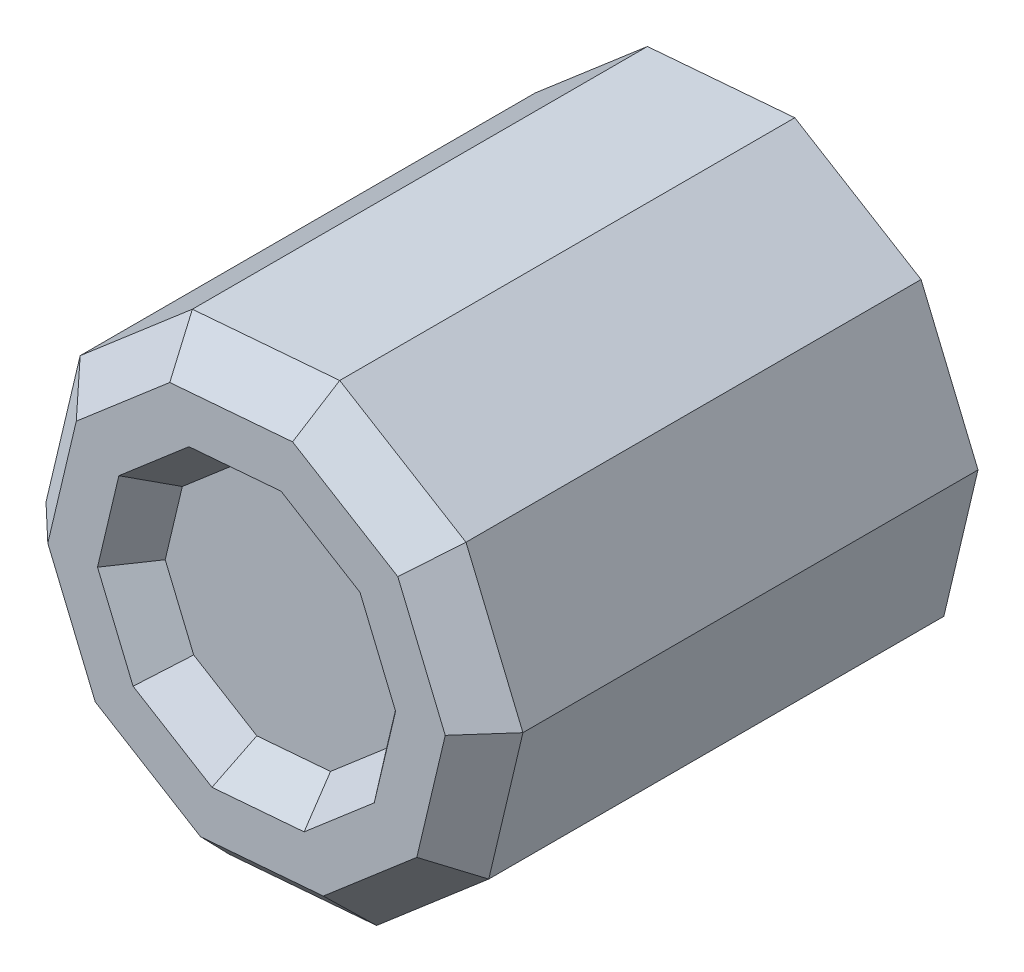
from build123d import *

# Parameters (mm, degrees)
SKETCH_1_R          = 3.05
EXTRUDE_1_DEPTH     = 12
SKETCH_2_R          = 3.098235282
EXTRUDE_2_DEPTH     = 2
EXTRUDE_3_DEPTH     = 7
CHAMFER_1_SIZE      = 1
SKETCH_6_R          = 3.05
CUT_EXTRUDE_2_DEPTH = 7
SKETCH_7_R          = 3.05
SKETCH_7_R_2        = 3
EXTRUDE_4_DEPTH     = 10
SKETCH_8_R          = 3
EXTRUDE_5_DEPTH     = 1


with BuildPart() as part:
    # 草图1 → 凸台-拉伸1 (new body)
    with BuildSketch(Plane.XY):
        Polygon((1.45714262, 6.138188374), (-2.429083459, 5.822385651), (-5.387482218, 3.282629506), (-6.288045884, -0.510979538), (-4.786789744, -4.109411766), (-1.45714262, -6.138188374), (2.429083459, -5.822385651), (5.387482218, -3.282629506), (6.288045884, 0.510979538), (4.786789744, 4.109411766), align=None)
        Circle(SKETCH_1_R, mode=Mode.SUBTRACT)
    extrude(amount=EXTRUDE_1_DEPTH)

    # 草图2 → 凸台-拉伸2 (add)
    with BuildSketch(Plane.XY.offset(12)):
        Circle(SKETCH_2_R)
    extrude(amount=-EXTRUDE_2_DEPTH)

    # 草图3 → 凸台-拉伸3 (add)
    with BuildSketch(Plane(origin=(0, 0, 10), x_dir=(-1, 0, 0), z_dir=(0, 0, -1))):
        with BuildLine():
            Line((1.45, 2.683281573), (1.45, -2.683281573))
            ThreePointArc((1.45, -2.683281573), (3.05, 0), (1.45, 2.683281573))
        make_face()
    extrude(amount=EXTRUDE_3_DEPTH)

    # 倒角1
    chamfer_1_edges = [part.edges().sort_by_distance(p)[0] for p in [
        (-3.908282839, 4.552507579, 12),
        (-5.837764051, 1.385824984, 12),
        (-5.537417814, -2.310195652, 12),
        (-3.121966182, -5.12380007, 12),
        (0.48597042, -5.980287012, 12),
        (3.908282839, -4.552507579, 12),
        (5.837764051, -1.385824984, 12),
        (5.537417814, 2.310195652, 12),
        (3.121966182, 5.12380007, 12),
        (-0.48597042, 5.980287012, 12),
    ]]
    chamfer(chamfer_1_edges, length=CHAMFER_1_SIZE)

    # 草图5 → 切除-放样1 section 0
    with BuildSketch(Plane.XY.offset(12)):
        Polygon((0.910714137, 3.836367733), (-1.518177162, 3.638991032), (-3.367176386, 2.051643441), (-3.930028677, -0.319362211), (-2.99174359, -2.568382354), (-0.910714137, -3.836367733), (1.518177162, -3.638991032), (3.367176386, -2.051643441), (3.930028677, 0.319362211), (2.99174359, 2.568382354), align=None)
    # 草图4 → 切除-放样1 section 1
    with BuildSketch(Plane.XY.offset(11)):
        Polygon((0.72857131, 3.069094187), (-1.21454173, 2.911192826), (-2.693741109, 1.641314753), (-3.144022942, -0.255489769), (-2.393394872, -2.054705883), (-0.72857131, -3.069094187), (1.21454173, -2.911192826), (2.693741109, -1.641314753), (3.144022942, 0.255489769), (2.393394872, 2.054705883), align=None)
    loft(mode=Mode.SUBTRACT)

    # 草图6 → 切除-拉伸2 (cut)
    with BuildSketch(Plane(origin=(0, 0, 3), x_dir=(-1, 0, 0), z_dir=(0, 0, -1))):
        Circle(SKETCH_6_R)
    extrude(amount=-CUT_EXTRUDE_2_DEPTH, mode=Mode.SUBTRACT)

    # 草图7 → 凸台-拉伸4 (add)
    with BuildSketch(Plane(origin=(0, 0, 0), x_dir=(-1, 0, 0), z_dir=(0, 0, -1))):
        Circle(SKETCH_7_R)
        Circle(SKETCH_7_R_2, mode=Mode.SUBTRACT)
    extrude(amount=-EXTRUDE_4_DEPTH)

    # 草图8 → 凸台-拉伸5 (add)
    with BuildSketch(Plane(origin=(0, 0, 0), x_dir=(-1, 0, 0), z_dir=(0, 0, -1))):
        Polygon((2.429083459, 5.822385651), (-1.45714262, 6.138188374), (-4.786789744, 4.109411766), (-6.288045884, 0.510979538), (-5.387482218, -3.282629506), (-2.429083459, -5.822385651), (1.45714262, -6.138188374), (4.786789744, -4.109411766), (6.288045884, -0.510979538), (5.387482218, 3.282629506), align=None)
        Circle(SKETCH_8_R, mode=Mode.SUBTRACT)
    extrude(amount=EXTRUDE_5_DEPTH)


solid = part.part
